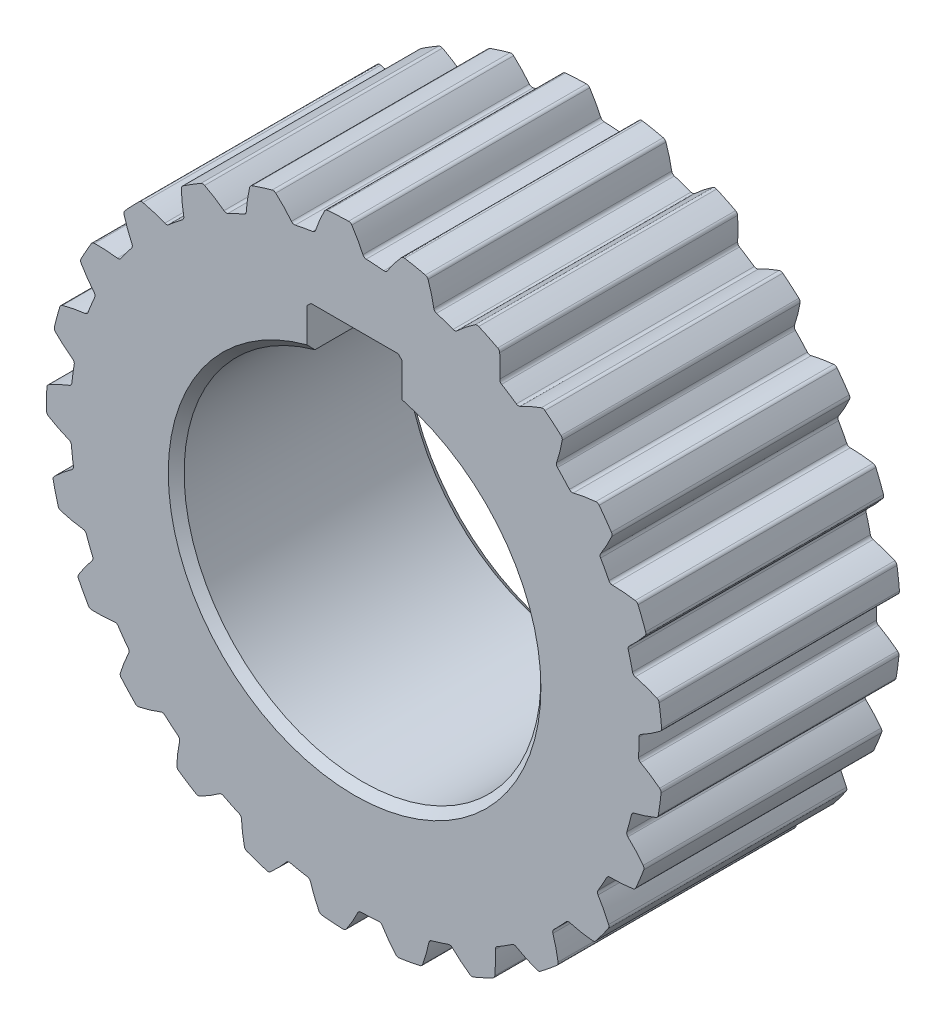
from build123d import *

# Parameters (mm, degrees)
SKETCH1_R                = 35.85
BOSS_EXTRUDE1_DEPTH      = 30
BOSS_EXTRUDE2_DEPTH      = 30
FILLET1_R                = 0.48
CIRPATTERN1_COUNT        = 25
FILLET1_OF_CIRPATTERN1_R = 0.48
CHAMFER1_SIZE            = 0.5
CHAMFER2_SIZE            = 1


with BuildPart() as part:
    # Sketch1 → Boss-Extrude1 (new body)
    with BuildSketch(Plane.XY):
        Circle(SKETCH1_R)
        with BuildLine():
            Line((6, 21.685248442), (6, 27.5))
            Line((6, 27.5), (-6, 27.5))
            Line((-6, 27.5), (-6, 21.685248442))
            ThreePointArc((-6, 21.685248442), (0, -22.5), (6, 21.685248442))
        make_face(mode=Mode.SUBTRACT)
    extrude(amount=BOSS_EXTRUDE1_DEPTH)

    # Sketch2 → Boss-Extrude2 (add)
    with BuildSketch(Plane.XY):
        with BuildLine():
            ThreePointArc((35.833660522, 1.082253952), (35.606652409, 4.169988514), (35.114077471, 7.226621848))
            add(Edge.make_bspline(
                [(35.114077471, 7.226621848), (35.137465191, 7.221030931), (35.277410926, 7.187262252), (35.533135946, 7.122159664), (35.900245875, 7.020630644), (36.362540181, 6.876985826), (36.808905507, 6.72706227), (37.270745226, 6.555639027), (37.69616913, 6.389406832), (38.053275563, 6.236162647), (38.260725023, 6.145338386), (38.367299222, 6.09750423), (38.368608389, 6.096916457)],
                knots=[0.405523248, 0.405523248, 0.405523248, 0.405523248, 0.405523248, 0.416499661, 0.471231937, 0.525964282, 0.580696616, 0.635428982, 0.690161387, 0.744893688, 0.799626082, 0.800306597, 0.800306597, 0.800306597, 0.800306597, 0.800306597], degree=4))
            ThreePointArc((38.368608389, 6.096916457), (38.586288594, 4.518941528), (38.739099664, 2.933369604))
            add(Edge.make_bspline(
                [(35.833660522, 1.082253952), (35.855123562, 1.09309746), (35.983479958, 1.158287705), (36.217242803, 1.280715501), (36.550959971, 1.464320222), (36.967554748, 1.710894048), (37.367200835, 1.95989622), (37.776934947, 2.233391762), (38.152438066, 2.493422623), (38.464473318, 2.725031747), (38.645323767, 2.861330829), (38.737961731, 2.932495244), (38.739099664, 2.933369604)],
                knots=[0.405523248, 0.405523248, 0.405523248, 0.405523248, 0.405523248, 0.416499661, 0.471231937, 0.525964282, 0.580696616, 0.635428982, 0.690161387, 0.744893688, 0.799626082, 0.800306597, 0.800306597, 0.800306597, 0.800306597, 0.800306597], degree=4))
        make_face()
    boss_extrude2 = extrude(amount=BOSS_EXTRUDE2_DEPTH)

    # Fillet1
    fillet1_edges = [part.edges().sort_by_distance(p)[0] for p in [
        (35.833660522, 1.082253952, 15),
        (38.739099664, 2.933369604, 15),
        (38.368608389, 6.096916457, 15),
        (35.114077471, 7.226621848, 15),
    ]]
    fillet(fillet1_edges, radius=FILLET1_R)

    # CirPattern1: Boss-Extrude2 ×25 about axis
    cirpattern1_axis = Axis((0, 0, 30), (0, 0, -1))
    for i in range(1, CIRPATTERN1_COUNT):
        add(boss_extrude2.rotate(cirpattern1_axis, i * 360 / CIRPATTERN1_COUNT))

    # Fillet1 of CirPattern1
    fillet1_of_cirpattern1_edges = [part.edges().sort_by_distance(p)[0] for p in [
        (34.977025796, -7.863216038, 15),
        (38.251538968, -6.79280992, 15),
        (38.679429467, -3.636514276, 15),
        (35.808091929, -1.73293173, 15),
        (31.922655903, -16.314611245, 15),
        (35.360493399, -16.092172215, 15),
        (36.559879739, -13.141449443, 15),
        (34.252152278, -10.583598835, 15),
        (26.862468137, -23.740899427, 15),
        (30.247617983, -24.380404147, 15),
        (32.143138309, -21.82065901, 15),
        (30.544023929, -18.769259501, 15),
        (20.114412704, -29.675459585, 15),
        (23.234173486, -31.136725621, 15),
        (25.706725285, -29.128796321, 15),
        (24.916702223, -25.775578564, 15),
        (12.102494746, -33.745401478, 15),
        (14.76084042, -35.936612112, 15),
        (17.655064168, -34.606664231, 15),
        (17.72377248, -31.16232323, 15),
        (3.330132532, -35.69499569, 15),
        (5.360029463, -38.478469098, 15),
        (8.494070439, -37.910068153, 15),
        (9.417192928, -34.59102452, 15),
        (-5.651474156, -35.401742046, 15),
        (-4.377571857, -38.602582357, 15),
        (-1.200636975, -38.831443069, 15),
        (0.51889651, -35.846244523, 15),
        (-14.277977937, -32.88406675, 15),
        (-13.840114238, -36.301153396, 15),
        (-10.819903952, -37.312895606, 15),
        (-8.412004084, -34.849113149, 15),
        (-22.007343855, -28.300164601, 15),
        (-22.433031341, -31.718789461, 15),
        (-19.75931657, -33.449841684, 15),
        (-16.814347524, -31.66228383, 15),
        (-28.35390742, -21.93805903, 15),
        (-29.616398582, -25.14341733, 15),
        (-27.45717866, -27.485011189, 15),
        (-24.16018367, -26.485996772, 15),
        (-32.918890704, -14.197504527, 15),
        (-34.938858579, -16.988191818, 15),
        (-33.429805233, -19.793196358, 15),
        (-29.987946621, -19.645497129, 15),
        (-35.415459018, -5.5648686, 15),
        (-38.065981594, -7.765535735, 15),
        (-37.301914198, -10.857702206, 15),
        (-33.931456599, -11.570598649, 15),
        (-35.686743793, 3.417428487, 15),
        (-38.80127899, 1.945057518, 15),
        (-38.830206706, -1.239978693, 15),
        (-35.742928366, -2.768676903, 15),
        (-33.715699208, 12.184995974, 15),
        (-37.098549325, 11.533435653, 15),
        (-37.91865452, 8.455657242, 15),
        (-35.308540492, 6.207210995, 15),
        (-29.626173245, 20.186935351, 15),
        (-33.064781368, 20.397125609, 15),
        (-34.624533815, 17.619993135, 15),
        (-32.655587162, 14.793076999, 15),
        (-23.675125859, 26.920455337, 15),
        (-26.953431593, 27.979189148, 15),
        (-29.154826311, 25.677200058, 15),
        (-27.950763193, 22.449439569, 15),
        (-16.236483245, 31.962464108, 15),
        (-19.148498584, 33.803217332, 15),
        (-21.853213845, 32.121014066, 15),
        (-21.489689976, 28.695221288, 15),
        (-7.777642674, 34.996153709, 15),
        (-10.140394985, 37.503265052, 15),
        (-13.178483583, 36.546546628, 15),
        (-13.678340504, 33.137976719, 15),
        (1.169895789, 35.830906266, 15),
        (-0.495133075, 38.846844701, 15),
        (-3.67570073, 38.675725257, 15),
        (-5.007530593, 35.498551201, 15),
        (10.043925398, 34.414271205, 15),
        (9.181239866, 37.749534229, 15),
        (6.058039917, 38.374765828, 15),
        (3.977920881, 35.628621156, 15),
        (18.286858235, 30.835260918, 15),
        (18.280721741, 34.280281689, 15),
        (15.411131637, 35.66257873, 15),
        (12.713424957, 33.520013811, 15),
        (25.380760515, 25.318757783, 15),
        (26.231558636, 28.657072975, 15),
        (23.795885278, 30.709580652, 15),
        (20.650097786, 29.30522072, 15),
        (30.879896268, 18.211383981, 15),
        (32.53417023, 21.233234974, 15),
        (30.685455932, 23.82698668, 15),
        (27.289249025, 23.249072834, 15),
        (34.43873457, 9.959721946, 15),
        (36.792540256, 12.475234728, 15),
        (35.646946536, 15.447255506, 15),
        (32.213716385, 15.732100198, 15),
    ]]
    fillet(fillet1_of_cirpattern1_edges, radius=FILLET1_OF_CIRPATTERN1_R)

    # Chamfer1
    chamfer1_edges = [part.edges().sort_by_distance(p)[0] for p in [
        (6, 27.5, 15),
        (-6, 27.5, 15),
    ]]
    chamfer(chamfer1_edges, length=CHAMFER1_SIZE)

    # Chamfer2
    chamfer2_edges = [part.edges().sort_by_distance(p)[0] for p in [
        (0, -22.5, 30),
        (0, -22.5, 0),
    ]]
    chamfer(chamfer2_edges, length=CHAMFER2_SIZE)


solid = part.part
